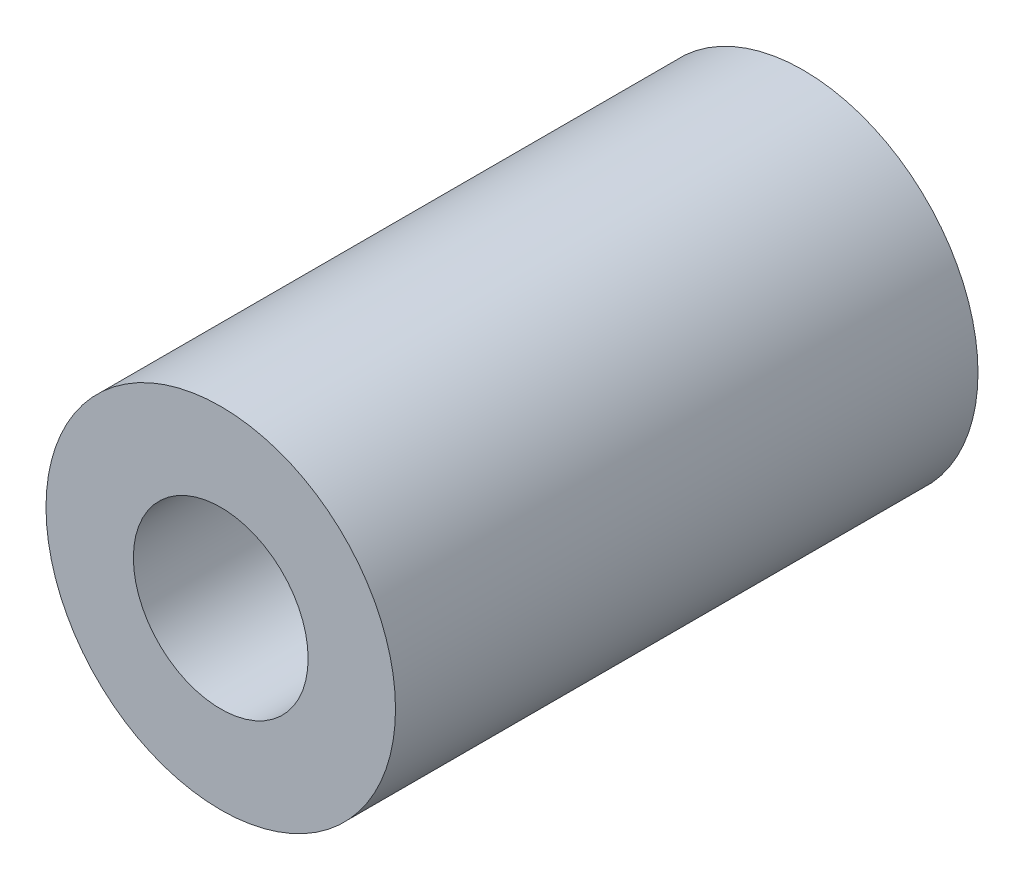
from build123d import *

# Parameters (mm, degrees)
SKETCH1_R           = 3
SKETCH1_R_2         = 1.5
BOSS_EXTRUDE1_DEPTH = 10


with BuildPart() as part:
    # Sketch1 → Boss-Extrude1 (new body)
    with BuildSketch(Plane.XY):
        Circle(SKETCH1_R)
        Circle(SKETCH1_R_2, mode=Mode.SUBTRACT)
    extrude(amount=BOSS_EXTRUDE1_DEPTH)


solid = part.part
